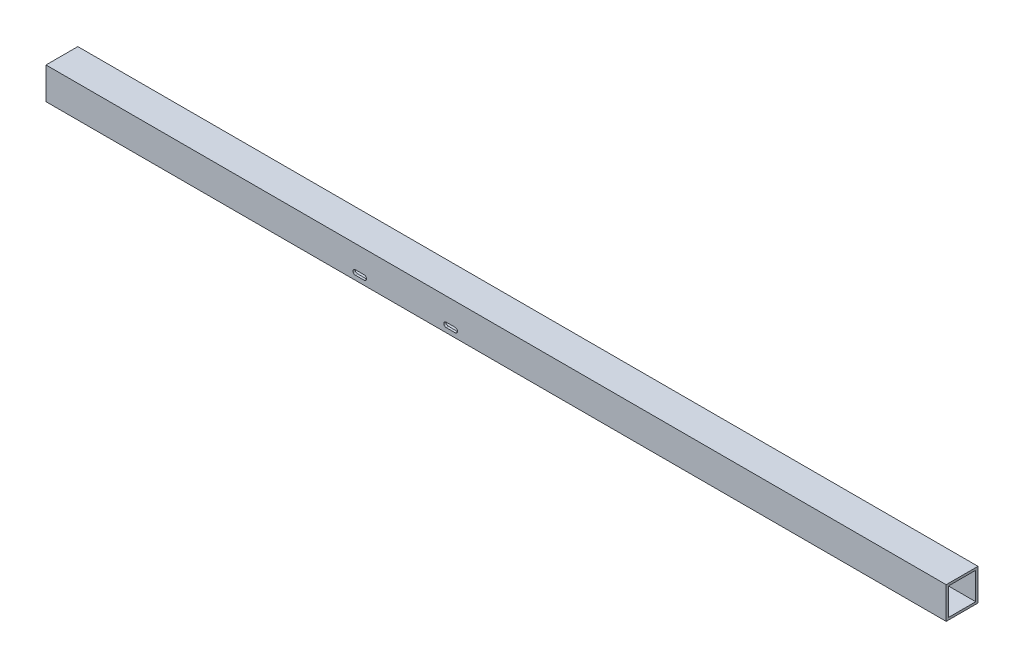
from build123d import *

# Parameters (mm, degrees)
SKETCH1_W           = 44.45
SKETCH1_H           = 44.45
SKETCH1_W_2         = 38.1
SKETCH1_H_2         = 38.1
BOSS_EXTRUDE1_DEPTH = 628.65
CUT_EXTRUDE1_REACH  = 46.45


with BuildPart() as part:
    # Sketch1 → Boss-Extrude1 (new body, symmetric)
    with BuildSketch(Plane(origin=(0, 0, 0), x_dir=(0, 0, -1), z_dir=(1, 0, 0))):
        with Locations((22.225, 22.225)):
            Rectangle(SKETCH1_W, SKETCH1_H)
        with Locations((22.225, 22.225)):
            Rectangle(SKETCH1_W_2, SKETCH1_H_2, mode=Mode.SUBTRACT)
    extrude(amount=BOSS_EXTRUDE1_DEPTH, both=True)

    # Sketch2 → Cut-Extrude1 (cut, up to next)
    with BuildSketch(Plane.XY, mode=Mode.PRIVATE) as cut_extrude1_sk1:
        with BuildLine():
            Line((-196.723, 12.827), (-184.277, 12.827))
            ThreePointArc((-184.277, 12.827), (-180.975, 9.525), (-184.277, 6.223))
            Line((-184.277, 6.223), (-196.723, 6.223))
            ThreePointArc((-196.723, 6.223), (-200.025, 9.525), (-196.723, 12.827))
        make_face()
    cut_extrude1_tool1 = extrude(cut_extrude1_sk1.sketch, amount=-CUT_EXTRUDE1_REACH, mode=Mode.PRIVATE) & part.part
    add(cut_extrude1_tool1.solids().sort_by_distance((-190.5, 9.525, 0))[0], mode=Mode.SUBTRACT)
    # Sketch2 → Cut-Extrude1 (cut, up to next)
    with BuildSketch(Plane.XY, mode=Mode.PRIVATE) as cut_extrude1_sk2:
        with BuildLine():
            Line((-69.723, 12.827), (-57.277, 12.827))
            ThreePointArc((-57.277, 12.827), (-53.975, 9.525), (-57.277, 6.223))
            Line((-57.277, 6.223), (-69.723, 6.223))
            ThreePointArc((-69.723, 6.223), (-73.025, 9.525), (-69.723, 12.827))
        make_face()
    cut_extrude1_tool2 = extrude(cut_extrude1_sk2.sketch, amount=-CUT_EXTRUDE1_REACH, mode=Mode.PRIVATE) & part.part
    add(cut_extrude1_tool2.solids().sort_by_distance((-63.5, 9.525, 0))[0], mode=Mode.SUBTRACT)


solid = part.part
